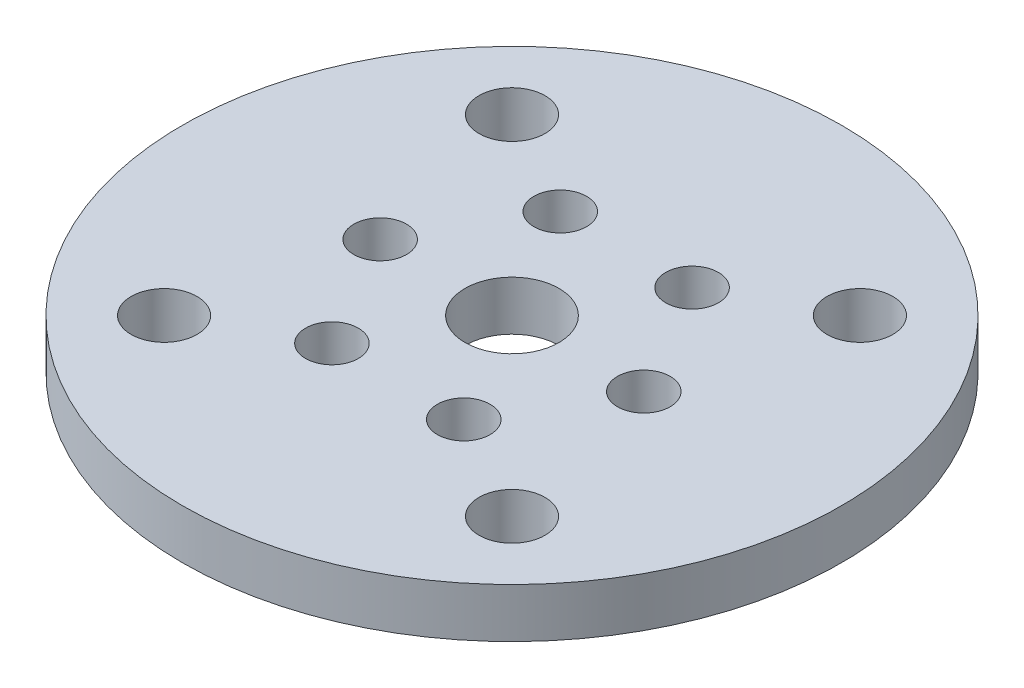
from build123d import *

# Parameters (mm, degrees)
ESBO_O1_R                = 20
ESBO_O1_R_2              = 2.85
ESBO_O1_R_3              = 2
ESBO_O1_R_4              = 1.6
RESSALTO_EXTRUS_O1_DEPTH = 3


with BuildPart() as part:
    # Esboço1 → Ressalto-extrusão1 (new body)
    with BuildSketch(Plane.XZ.offset(3)):
        Circle(ESBO_O1_R)
        Circle(ESBO_O1_R_2, mode=Mode.SUBTRACT)
        with Locations((10.557104243, 10.557104243)):
            Circle(ESBO_O1_R_3, mode=Mode.SUBTRACT)
        with Locations((10.557104243, -10.557104243)):
            Circle(ESBO_O1_R_3, mode=Mode.SUBTRACT)
        with Locations((-10.557104243, -10.557104243)):
            Circle(ESBO_O1_R_3, mode=Mode.SUBTRACT)
        with Locations((-10.557104243, 10.557104243)):
            Circle(ESBO_O1_R_3, mode=Mode.SUBTRACT)
        with Locations((-8, 0)):
            Circle(ESBO_O1_R_4, mode=Mode.SUBTRACT)
        with Locations((-4, 6.92820323)):
            Circle(ESBO_O1_R_4, mode=Mode.SUBTRACT)
        with Locations((4, 6.92820323)):
            Circle(ESBO_O1_R_4, mode=Mode.SUBTRACT)
        with Locations((8, 0)):
            Circle(ESBO_O1_R_4, mode=Mode.SUBTRACT)
        with Locations((4, -6.92820323)):
            Circle(ESBO_O1_R_4, mode=Mode.SUBTRACT)
        with Locations((-4, -6.92820323)):
            Circle(ESBO_O1_R_4, mode=Mode.SUBTRACT)
    extrude(amount=-RESSALTO_EXTRUS_O1_DEPTH)


solid = part.part
